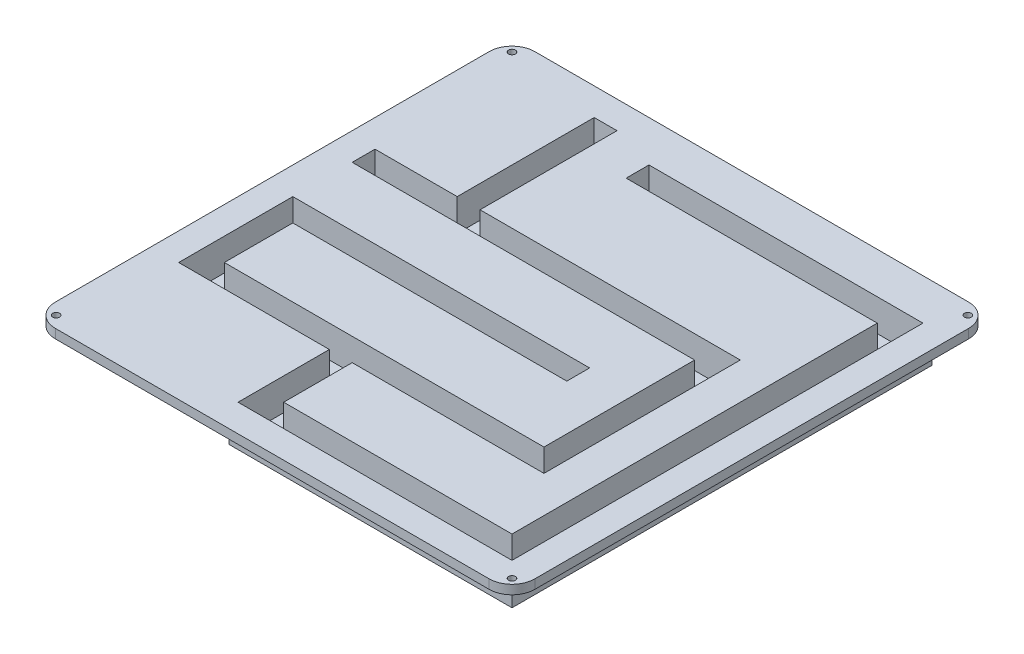
from build123d import *

# Parameters (mm, degrees)
SKETCH1_W           = 210
SKETCH1_H           = 210
MAINEXTRUDE_DEPTH   = 4
SKETCH1_6_R         = 1.5
SCREWHOLES_DEPTH    = 4
ROUNDEDCORNERS_R    = 10
TRENCH_DEPTH        = 12
TRENCH_WALLS_DEPTH  = 10
TRENCH_BOTTOM_DEPTH = 2


with BuildPart() as part:
    # Sketch1 → MainExtrude (new body)
    with BuildSketch(Plane(origin=(0, 0, 0), x_dir=(1, 0, 0), z_dir=(0, 1, 0))):
        Rectangle(SKETCH1_W, SKETCH1_H)
    extrude(amount=MAINEXTRUDE_DEPTH)

    # Sketch1_6 → ScrewHoles (cut)
    with BuildSketch(Plane(origin=(0, 0, 0), x_dir=(1, 0, 0), z_dir=(0, 1, 0))):
        with Locations((-99.833273811, 99.833273811)):
            Circle(SKETCH1_6_R)
        with Locations((-99.833273811, -99.833273811)):
            Circle(SKETCH1_6_R)
        with Locations((99.833273811, -99.833273811)):
            Circle(SKETCH1_6_R)
        with Locations((99.833273811, 99.833273811)):
            Circle(SKETCH1_6_R)
    extrude(amount=SCREWHOLES_DEPTH, mode=Mode.SUBTRACT)

    # RoundedCorners
    roundedcorners_edges = [part.edges().sort_by_distance(p)[0] for p in [
        (-105, 2, -105),
        (-105, 2, 105),
        (105, 2, 105),
        (105, 2, -105),
    ]]
    fillet(roundedcorners_edges, radius=ROUNDEDCORNERS_R)

    # Sketch3 → Trench (cut)
    with BuildSketch(Plane(origin=(0, 0, 0), x_dir=(1, 0, 0), z_dir=(0, 1, 0))):
        Polygon((-57, 93), (-57, 33), (-93, 33), (-93, 23), (57, 23), (57, -43), (-83, -43), (-83, -13), (37, -13), (37, -3), (-93, -3), (-93, -53), (-27, -53), (-27, -93), (93, -93), (93, 87), (-27, 87), (-27, 77), (83, 77), (83, -83), (-17, -83), (-17, -53), (67, -53), (67, 33), (-47, 33), (-47, 93), align=None)
    extrude(amount=TRENCH_DEPTH, mode=Mode.SUBTRACT)

    # Sketch7 → Trench Walls (add)
    with BuildSketch(Plane.XZ):
        Polygon((-59, -95), (-45, -95), (-45, -35), (69, -35), (69, 55), (-15, 55), (-15, 81), (81, 81), (81, -75), (-29, -75), (-29, -89), (95, -89), (95, 95), (-29, 95), (-29, 55), (-95, 55), (-95, 1), (39, 1), (39, 15), (-81, 15), (-81, 41), (55, 41), (55, -21), (-95, -21), (-95, -35), (-59, -35), align=None)
        Polygon((-57, -93), (-47, -93), (-47, -33), (67, -33), (67, 53), (-17, 53), (-17, 83), (83, 83), (83, -77), (-27, -77), (-27, -87), (93, -87), (93, 93), (-27, 93), (-27, 53), (-93, 53), (-93, 3), (37, 3), (37, 13), (-83, 13), (-83, 43), (57, 43), (57, -23), (-93, -23), (-93, -33), (-57, -33), align=None, mode=Mode.SUBTRACT)
    extrude(amount=TRENCH_WALLS_DEPTH)

    # Sketch8 → Trench Bottom (add)
    with BuildSketch(Plane.XZ.offset(10)):
        Polygon((-59, -35), (-59, -95), (-45, -95), (-45, -35), (69, -35), (69, 55), (-15, 55), (-15, 81), (81, 81), (81, -75), (-29, -75), (-29, -89), (95, -89), (95, 95), (-29, 95), (-29, 55), (-95, 55), (-95, 1), (39, 1), (39, 15), (-81, 15), (-81, 41), (55, 41), (55, -21), (-95, -21), (-95, -35), align=None)
    extrude(amount=TRENCH_BOTTOM_DEPTH)


solid = part.part
